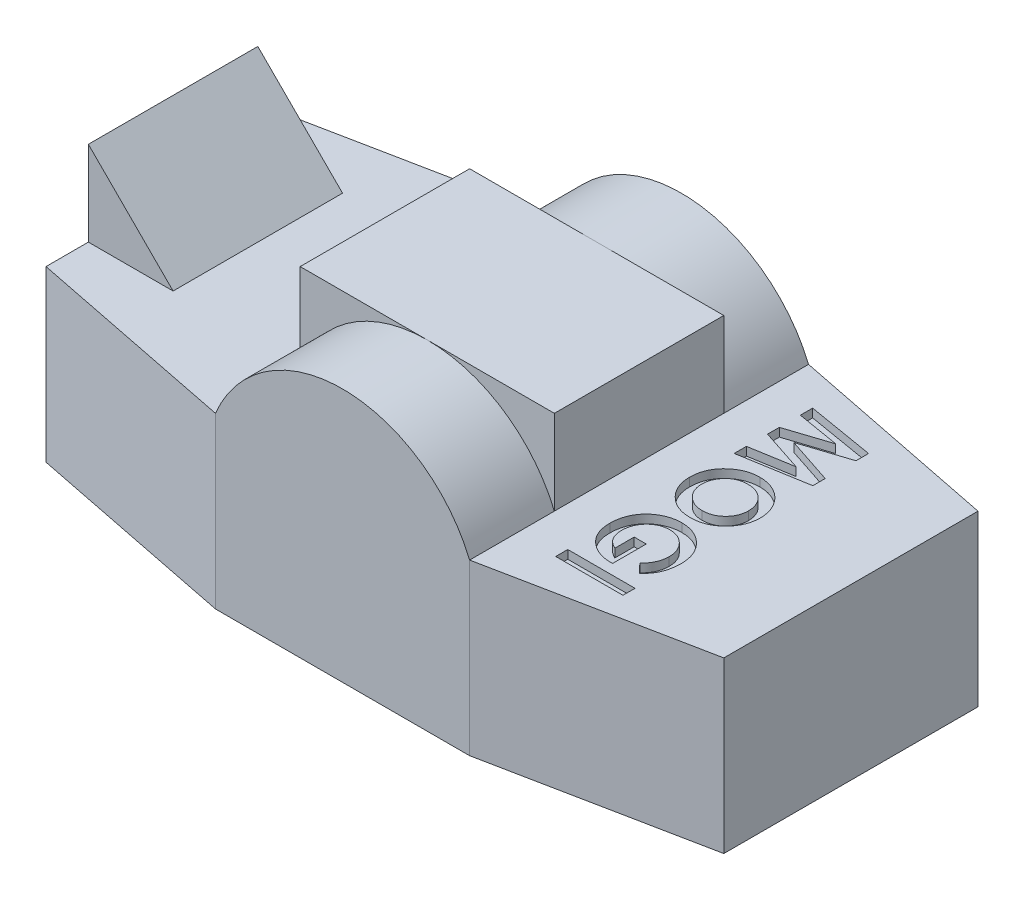
from build123d import *

# Parameters (mm, degrees)
SKETCH1_W                = 150
SKETCH1_H                = 200
BOSS_EXTRUDE1_DEPTH      = 50
BOSS_EXTRUDE2_DEPTH      = 50
SKETCH3_W                = 150
SKETCH3_H                = 50
BOSS_EXTRUDE3_DEPTH      = 50
BOSS_EXTRUDE3_DEPTH_BACK = 50
SKETCH4_W                = 39.6875
SKETCH4_H                = 7.123397436
CUT_EXTRUDE1_DEPTH       = 5
BOSS_EXTRUDE4_DEPTH      = 50


with BuildPart() as part:
    # Sketch1 → Boss-Extrude1 (new body)
    with BuildSketch(Plane(origin=(0, 0, 0), x_dir=(1, 0, 0), z_dir=(0, 1, 0))):
        Polygon((-75, -100), (-75, 100), (-200, 75), (-200, -75), align=None)
        Rectangle(SKETCH1_W, SKETCH1_H)
        Polygon((200, 75), (75, 100), (75, -100), (200, -75), align=None)
    extrude(amount=BOSS_EXTRUDE1_DEPTH)

    # Sketch2 → Boss-Extrude2 (add)
    with BuildSketch(Plane.XY.offset(100)):
        with BuildLine():
            Line((-75, 50), (75, 50))
            ThreePointArc((75, 50), (0, 100), (-75, 50))
        make_face()
    boss_extrude2 = extrude(amount=-BOSS_EXTRUDE2_DEPTH)

    # Mirror1: Boss-Extrude2 across plane
    add(boss_extrude2.mirror(Plane.XY))

    # Sketch3 → Boss-Extrude3 (add, two sides)
    with BuildSketch(Plane.XY) as boss_extrude3_sk:
        Polygon((-200, 50), (-200, 100), (-150, 50), align=None)
        with Locations((0, 75)):
            Rectangle(SKETCH3_W, SKETCH3_H)
    extrude(amount=BOSS_EXTRUDE3_DEPTH)
    extrude(boss_extrude3_sk.sketch, amount=-BOSS_EXTRUDE3_DEPTH_BACK)

    # Sketch4 → Cut-Extrude1 (cut)
    with BuildSketch(Plane(origin=(0, 50, 0), x_dir=(1, 0, 0), z_dir=(0, 1, 0))):
        Polygon((138.238090056, 72.16415014), (138.238090056, 64.770445212), (110.555422789, 55.715144231), (138.238090056, 46.596241486), (138.238090056, 39.274088542), (98.550590056, 32.564102564), (98.550590056, 39.774952424), (123.617634828, 44.012419872), (98.550590056, 52.264748598), (98.550590056, 59.213241186), (123.617634828, 67.41786859), (98.550590056, 71.647385817), (98.550590056, 78.866185897), align=None)
        with BuildLine():
            add(Edge.make_bspline(
                [(139.255718261, 7.298302284), (139.237863172, 6.608280864), (139.202613181, 5.246022296), (138.908448021, 3.242728383), (138.429966869, 1.311808244), (137.761136479, -0.546328966), (136.897803874, -2.329159415), (135.83641455, -4.032112704), (134.593491556, -5.666182695), (133.17131794, -7.201201967), (131.617228092, -8.60922769), (129.960285603, -9.847208368), (128.218977715, -10.895236079), (126.394848429, -11.752287482), (124.484098833, -12.415940369), (122.487726636, -12.879186723), (120.409416627, -13.1774979), (118.994294011, -13.211755791), (118.275086751, -13.229166667)],
                knots=[0, 0, 0, 0, 0.002069258, 0.004085183, 0.006059673, 0.008028778, 0.009998652, 0.011990861, 0.014038887, 0.016148694, 0.018259518, 0.020321815, 0.022343815, 0.02434615, 0.026357571, 0.028399726, 0.030486503, 0.032643124, 0.032643124, 0.032643124, 0.032643124], degree=3))
            add(Edge.make_bspline(
                [(118.275086751, -13.229166667), (117.563982501, -13.210624952), (116.16272876, -13.174087908), (114.103582646, -12.891344074), (112.128553779, -12.420340175), (110.236510272, -11.767686463), (108.427041433, -10.927135252), (106.70203699, -9.897607151), (105.068072705, -8.669706632), (103.529157895, -7.283891201), (102.132691672, -5.758196669), (100.898705456, -4.141636446), (99.860561661, -2.437425307), (99.00314768, -0.657607728), (98.340278964, 1.20559829), (97.872131449, 3.1479631), (97.587737583, 5.169815778), (97.551404055, 6.544756913), (97.532961851, 7.242650741)],
                knots=[0, 0, 0, 0, 0.002132794, 0.004202739, 0.006221688, 0.008215482, 0.010196683, 0.01219687, 0.014230542, 0.016318909, 0.018400865, 0.020426612, 0.022410491, 0.024376913, 0.026343336, 0.028331368, 0.030361929, 0.032455013, 0.032455013, 0.032455013, 0.032455013], degree=3))
            add(Edge.make_bspline(
                [(97.532961851, 7.242650741), (97.549503316, 7.972565498), (97.582005033, 9.406748226), (97.891081523, 11.505681067), (98.356658686, 13.516640092), (99.051507626, 15.422732088), (99.920127229, 17.243368971), (100.989884346, 18.965173988), (102.259011122, 20.587568499), (103.69500475, 22.101246184), (105.266296739, 23.472641832), (106.926227384, 24.683167492), (108.662116277, 25.704272739), (110.474775848, 26.535994935), (112.352940861, 27.191691302), (114.308049881, 27.65421059), (116.335413849, 27.92743177), (117.712439982, 27.965489893), (118.410240497, 27.984775641)],
                knots=[0, 0, 0, 0, 0.002188391, 0.004299889, 0.006351616, 0.008370988, 0.01037296, 0.012393818, 0.014438942, 0.016542192, 0.018643774, 0.020687228, 0.022697046, 0.02467491, 0.026661193, 0.028655098, 0.030692465, 0.032785548, 0.032785548, 0.032785548, 0.032785548], degree=3))
            add(Edge.make_bspline(
                [(118.410240497, 27.984775641), (118.879664472, 27.978640908), (119.812568438, 27.966449121), (121.195431474, 27.82274393), (122.549367258, 27.609745684), (123.876702875, 27.317671816), (125.172453413, 26.926661822), (126.439371507, 26.445138537), (127.68237788, 25.89121074), (128.889476281, 25.245689823), (130.049022226, 24.527491815), (131.155704187, 23.743997389), (132.196050374, 22.893063462), (133.177101338, 21.977603351), (134.091685081, 20.9939439), (134.95685078, 19.955270534), (135.737719173, 18.835622475), (136.470651292, 17.671412336), (137.127412682, 16.464661012), (137.693350873, 15.222284581), (138.181423007, 13.963337774), (138.568867295, 12.672699054), (138.884015522, 11.365365563), (139.092525564, 10.027660648), (139.237419795, 8.67159221), (139.249604297, 7.757151956), (139.255718261, 7.298302284)],
                knots=[0, 0, 0, 0, 0.00140775, 0.002797675, 0.004166153, 0.005518275, 0.006871448, 0.008222541, 0.009581913, 0.010951221, 0.012325713, 0.013671345, 0.015016084, 0.016354794, 0.017693503, 0.019043286, 0.020406488, 0.021785181, 0.023169022, 0.024524435, 0.025878355, 0.027216309, 0.028564241, 0.029909168, 0.031275358, 0.03265132, 0.03265132, 0.03265132, 0.03265132], degree=3))
        make_face()
        with BuildLine():
            add(Edge.make_bspline(
                [(132.132320826, 7.409605369), (132.119860437, 7.873985907), (132.095268616, 8.79048726), (131.907912658, 10.134828221), (131.608682727, 11.425441543), (131.175255989, 12.655179774), (130.623598896, 13.829347091), (129.955705755, 14.950120771), (129.148363162, 16.001617019), (128.245880197, 16.999258298), (127.236152847, 17.897423805), (126.165847525, 18.704996256), (125.009210887, 19.35795136), (123.804339415, 19.919399534), (122.520763186, 20.334115847), (121.17931454, 20.649879073), (119.766222548, 20.821864588), (118.805525306, 20.848019351), (118.314837853, 20.861378205)],
                knots=[0, 0, 0, 0, 0.001392742, 0.002748715, 0.004063869, 0.005361291, 0.006652315, 0.00795032, 0.009266892, 0.010623122, 0.01197991, 0.013315571, 0.014636958, 0.015956839, 0.017296846, 0.018675745, 0.020085873, 0.021558038, 0.021558038, 0.021558038, 0.021558038], degree=3))
            add(Edge.make_bspline(
                [(118.314837853, 20.861378205), (117.770878808, 20.845176619), (116.704809211, 20.813424195), (115.149084816, 20.592244269), (113.682949823, 20.20808727), (112.301344977, 19.673595328), (111.011329535, 18.978378481), (109.805946186, 18.135531019), (108.691073928, 17.137574691), (108.039795818, 16.369681859), (107.709243902, 15.979942909)],
                knots=[0, 0, 0, 0, 0.001631733, 0.003197927, 0.004702032, 0.006169553, 0.007631464, 0.009087136, 0.010573338, 0.012105072, 0.012105072, 0.012105072, 0.012105072], degree=3))
            add(Edge.make_bspline(
                [(107.709243902, 15.979942909), (107.465071214, 15.660614125), (106.982227089, 15.029151091), (106.363363291, 14.021198607), (105.83293528, 12.983206023), (105.404355722, 11.907340385), (105.067242246, 10.795873865), (104.831167221, 9.648958879), (104.683009728, 8.468220509), (104.665302101, 7.669749887), (104.656359287, 7.266501402)],
                knots=[0, 0, 0, 0, 0.001205291, 0.002383427, 0.003542524, 0.004698482, 0.005852908, 0.00702232, 0.008207623, 0.009416997, 0.009416997, 0.009416997, 0.009416997], degree=3))
            add(Edge.make_bspline(
                [(104.656359287, 7.266501402), (104.668924664, 6.810105388), (104.693647437, 5.912131875), (104.878706396, 4.592823849), (105.191843365, 3.32885429), (105.621596335, 2.112529839), (106.179698099, 0.94678648), (106.871251429, -0.162314638), (107.676194333, -1.222886792), (108.594237849, -2.218783291), (109.604444057, -3.12829208), (110.685907098, -3.924122411), (111.824933224, -4.600136526), (113.022339506, -5.14819667), (114.27772972, -5.583779265), (115.592876424, -5.879331618), (116.963050603, -6.06980139), (117.895476491, -6.093630026), (118.370489395, -6.105769231)],
                knots=[0, 0, 0, 0, 0.001368916, 0.002693386, 0.003987221, 0.005269649, 0.006556897, 0.007856388, 0.009184098, 0.0105457, 0.011913715, 0.013255773, 0.014567439, 0.015880092, 0.017200044, 0.018546169, 0.019917899, 0.021342409, 0.021342409, 0.021342409, 0.021342409], degree=3))
            add(Edge.make_bspline(
                [(118.370489395, -6.105769231), (118.842773071, -6.093213907), (119.772391458, -6.068500667), (121.139011175, -5.883125245), (122.448468466, -5.571940349), (123.702901813, -5.141022703), (124.903541028, -4.590763687), (126.046163952, -3.910312592), (127.129665949, -3.102057035), (128.146663367, -2.18459897), (129.081218849, -1.186002254), (129.892243123, -0.1139089), (130.596997431, 1.001682716), (131.149073499, 2.186369708), (131.58891133, 3.415914373), (131.912814221, 4.697819457), (132.093952476, 6.036940255), (132.119417374, 6.947971822), (132.132320826, 7.409605369)],
                knots=[0, 0, 0, 0, 0.001416568, 0.002788298, 0.004128493, 0.005448446, 0.006761099, 0.008083658, 0.009430441, 0.010809683, 0.012187918, 0.013526769, 0.014837205, 0.01613881, 0.017438883, 0.018750067, 0.020098163, 0.021482963, 0.021482963, 0.021482963, 0.021482963], degree=3))
        make_face(mode=Mode.SUBTRACT)
        with BuildLine():
            Line((131.925615096, -56.724822216), (126.765922088, -51.334572817))
            add(Edge.make_bspline(
                [(126.765922088, -51.334572817), (127.193188867, -50.907817366), (128.031556826, -50.070452717), (129.122750341, -48.701047584), (130.050480548, -47.282759469), (130.813325217, -45.810920216), (131.405053866, -44.283479545), (131.828336302, -42.70345175), (132.079392287, -41.068266328), (132.11453927, -39.961318788), (132.132320826, -39.401292067)],
                knots=[0, 0, 0, 0, 0.001810487, 0.003552474, 0.005241592, 0.006887902, 0.008516378, 0.010145941, 0.011786405, 0.013466179, 0.013466179, 0.013466179, 0.013466179], degree=3))
            add(Edge.make_bspline(
                [(132.132320826, -39.401292067), (132.119860672, -38.915766542), (132.095394067, -37.962394612), (131.90961668, -36.561497506), (131.599231006, -35.222888572), (131.169426059, -33.940083794), (130.609452251, -32.721502321), (129.93196908, -31.559738736), (129.120027152, -30.468069093), (128.206359994, -29.441826035), (127.201277649, -28.509447048), (126.134760912, -27.684162696), (125.009166675, -26.990916876), (123.830900245, -26.418503842), (122.597643083, -25.983564768), (121.311020804, -25.672919873), (119.974575914, -25.475776306), (119.062846723, -25.452496572), (118.601045786, -25.440705128)],
                knots=[0, 0, 0, 0, 0.00145628, 0.002859533, 0.004230687, 0.005573215, 0.006910862, 0.008247114, 0.009600287, 0.010985452, 0.012363687, 0.013707368, 0.015024564, 0.016322423, 0.017629987, 0.018939265, 0.020288463, 0.021673262, 0.021673262, 0.021673262, 0.021673262], degree=3))
            add(Edge.make_bspline(
                [(118.601045786, -25.440705128), (118.123290492, -25.451780158), (117.182047162, -25.473599484), (115.800218097, -25.680628145), (114.473662759, -26.00516531), (113.20083485, -26.459475705), (111.985353173, -27.051725593), (110.829269262, -27.780915841), (109.727458618, -28.636268501), (108.695115745, -29.610348732), (107.743856367, -30.670376392), (106.922707251, -31.818074848), (106.217401667, -33.017637843), (105.650392818, -34.288503647), (105.205741651, -35.614461694), (104.886073022, -37.003912808), (104.691757127, -38.452329976), (104.668276024, -39.440438637), (104.656359287, -39.941907051)],
                knots=[0, 0, 0, 0, 0.001432452, 0.002822127, 0.004181522, 0.00552438, 0.006868414, 0.008229412, 0.009617699, 0.011046307, 0.012482307, 0.013883397, 0.015272867, 0.01665, 0.018050345, 0.019462019, 0.020921485, 0.022425422, 0.022425422, 0.022425422, 0.022425422], degree=3))
            add(Edge.make_bspline(
                [(104.656359287, -39.941907051), (104.65930536, -40.2680999), (104.665089156, -40.908489043), (104.75884391, -41.847850936), (104.893082074, -42.747457708), (105.070081736, -43.611145184), (105.323909089, -44.431309537), (105.611144145, -45.219081531), (105.967015968, -45.96411371), (106.370867876, -46.672899076), (106.835993015, -47.346080254), (107.360299572, -47.981482537), (107.948560749, -48.581244814), (108.58949979, -49.155701015), (109.301837025, -49.685347384), (110.067914394, -50.188918733), (110.896219364, -50.659805529), (111.48109075, -50.938069568), (111.779756723, -51.080165765)],
                knots=[0, 0, 0, 0, 0.000978168, 0.001920361, 0.002828846, 0.003706724, 0.004561881, 0.005402126, 0.006220072, 0.00703558, 0.007847126, 0.008671652, 0.009503733, 0.010365333, 0.011250989, 0.012163881, 0.013114489, 0.014106484, 0.014106484, 0.014106484, 0.014106484], degree=3))
            Line((111.779756723, -51.080165765), (111.779756723, -39.6875))
            Line((111.779756723, -39.6875), (118.903154159, -39.6875))
            Line((118.903154159, -39.6875), (118.903154159, -59.475598458))
            Line((118.903154159, -59.475598458), (117.209757224, -59.53125))
            add(Edge.make_bspline(
                [(117.209757224, -59.53125), (116.774849925, -59.524099191), (115.905811456, -59.509810334), (114.611961224, -59.379225169), (113.33527123, -59.162912832), (112.077023753, -58.867193161), (110.831046637, -58.496581607), (109.609271149, -58.023935861), (108.403411615, -57.470470582), (107.218592005, -56.850352003), (106.081725375, -56.153517142), (105.005262752, -55.403272095), (103.99106726, -54.610312117), (103.053269183, -53.757390657), (102.183990603, -52.857789104), (101.38657574, -51.909736583), (100.660349882, -50.909879881), (99.999178079, -49.863515638), (99.419700004, -48.764683802), (98.915630954, -47.619425747), (98.487535754, -46.429470657), (98.136590816, -45.191746348), (97.865808878, -43.908688353), (97.680133346, -42.580269184), (97.553964737, -41.205759258), (97.540047451, -40.27345825), (97.532961851, -39.798803085)],
                knots=[0, 0, 0, 0, 0.001304442, 0.002606556, 0.003896576, 0.005186693, 0.006481994, 0.007793106, 0.009112986, 0.0104608, 0.011802481, 0.01311031, 0.014395421, 0.015661804, 0.016910014, 0.018145781, 0.01937501, 0.020614658, 0.021855835, 0.023098157, 0.024365612, 0.025646585, 0.026954801, 0.028296128, 0.029668756, 0.031092401, 0.031092401, 0.031092401, 0.031092401], degree=3))
            add(Edge.make_bspline(
                [(97.532961851, -39.798803085), (97.540024418, -39.292390029), (97.554024532, -38.288528308), (97.682752519, -36.80659121), (97.900394148, -35.365902414), (98.191868648, -33.968713662), (98.56779726, -32.608846711), (99.023698707, -31.291402424), (99.581626303, -30.021156521), (100.2031128, -28.790156754), (100.914721627, -27.613762042), (101.689839622, -26.491364909), (102.54525722, -25.438278722), (103.472233383, -24.450093988), (104.462708443, -23.519788414), (105.530003189, -22.65646607), (106.663812292, -21.852362186), (107.871671263, -21.127169985), (109.120604151, -20.468539919), (110.403259482, -19.894900816), (111.70969394, -19.408612866), (113.040193895, -19.010044465), (114.394727569, -18.70004138), (115.772472911, -18.475038734), (117.17558709, -18.348721913), (118.118495111, -18.327825586), (118.593095565, -18.317307692)],
                knots=[0, 0, 0, 0, 0.001519012, 0.003011135, 0.004458185, 0.005888009, 0.007290249, 0.008688222, 0.010066204, 0.011449314, 0.012822311, 0.014187459, 0.015538365, 0.016888311, 0.018249495, 0.019611583, 0.02100344, 0.022415986, 0.023834894, 0.025237044, 0.02662815, 0.028014068, 0.029400715, 0.030794001, 0.03219901, 0.033622899, 0.033622899, 0.033622899, 0.033622899], degree=3))
            add(Edge.make_bspline(
                [(118.593095565, -18.317307692), (119.240558599, -18.331371428), (120.519106131, -18.359143137), (122.402414755, -18.616351306), (124.224327936, -19.017300521), (125.978210386, -19.592703014), (127.666478099, -20.331080289), (129.293094364, -21.221972563), (130.856330231, -22.284731952), (131.824190345, -23.107380711), (132.315175894, -23.524702023)],
                knots=[0, 0, 0, 0, 0.001941482, 0.003833852, 0.005691296, 0.007531631, 0.00936165, 0.011211849, 0.013088404, 0.015020488, 0.015020488, 0.015020488, 0.015020488], degree=3))
            add(Edge.make_bspline(
                [(132.315175894, -23.524702023), (132.599225916, -23.783812749), (133.163060937, -24.298143642), (133.94652117, -25.120300639), (134.683002775, -25.963307767), (135.35688912, -26.838840811), (135.982931902, -27.742297254), (136.549395448, -28.676277403), (137.074316258, -29.635881815), (137.530889887, -30.628594242), (137.940246232, -31.649217697), (138.286619257, -32.702272361), (138.593423429, -33.779871071), (138.826822716, -34.891555999), (139.02117983, -36.026096476), (139.151448147, -37.191545848), (139.24692555, -38.384728197), (139.252764174, -39.191736727), (139.255718261, -39.600047576)],
                knots=[0, 0, 0, 0, 0.001153111, 0.002288908, 0.003404774, 0.004509969, 0.005601584, 0.006700557, 0.00778555, 0.008881095, 0.009976525, 0.01108272, 0.012205364, 0.013335889, 0.014488671, 0.015657246, 0.016852981, 0.018077547, 0.018077547, 0.018077547, 0.018077547], degree=3))
            add(Edge.make_bspline(
                [(139.255718261, -39.600047576), (139.249136003, -40.026864978), (139.236039726, -40.876074885), (139.145422033, -42.138709385), (139.005620292, -43.383798732), (138.795909696, -44.606095997), (138.537292884, -45.809703218), (138.205940738, -46.988390234), (137.829465014, -48.149846517), (137.529310754, -48.90595016), (137.379466258, -49.283415966)],
                knots=[0, 0, 0, 0, 0.00128038, 0.002547487, 0.00379595, 0.005037611, 0.006266428, 0.007487375, 0.008709229, 0.0099273, 0.0099273, 0.0099273, 0.0099273], degree=3))
            add(Edge.make_bspline(
                [(137.379466258, -49.283415966), (137.240982972, -49.601006748), (136.959311798, -50.246977613), (136.443981175, -51.186785605), (135.872678034, -52.128889807), (135.224514206, -53.063124433), (134.500702059, -53.988065972), (133.712674081, -54.913371798), (132.851241417, -55.829596058), (132.238153042, -56.422548892), (131.925615096, -56.724822216)],
                knots=[0, 0, 0, 0, 0.001038927, 0.002113148, 0.003212121, 0.004343457, 0.005521861, 0.006734289, 0.007988536, 0.009292808, 0.009292808, 0.009292808, 0.009292808], degree=3))
        make_face()
        with Locations((118.394340056, -69.198717949)):
            Rectangle(SKETCH4_W, SKETCH4_H)
    extrude(amount=-CUT_EXTRUDE1_DEPTH, mode=Mode.SUBTRACT)

    # Sketch6 → Boss-Extrude4 (add)
    with BuildSketch(Plane.XZ):
        Polygon((-75, 100), (-200, 75), (-200, -75), (-75, -100), (75, -100), (200, -75), (200, 75), (75, 100), align=None)
    extrude(amount=BOSS_EXTRUDE4_DEPTH)


solid = part.part
